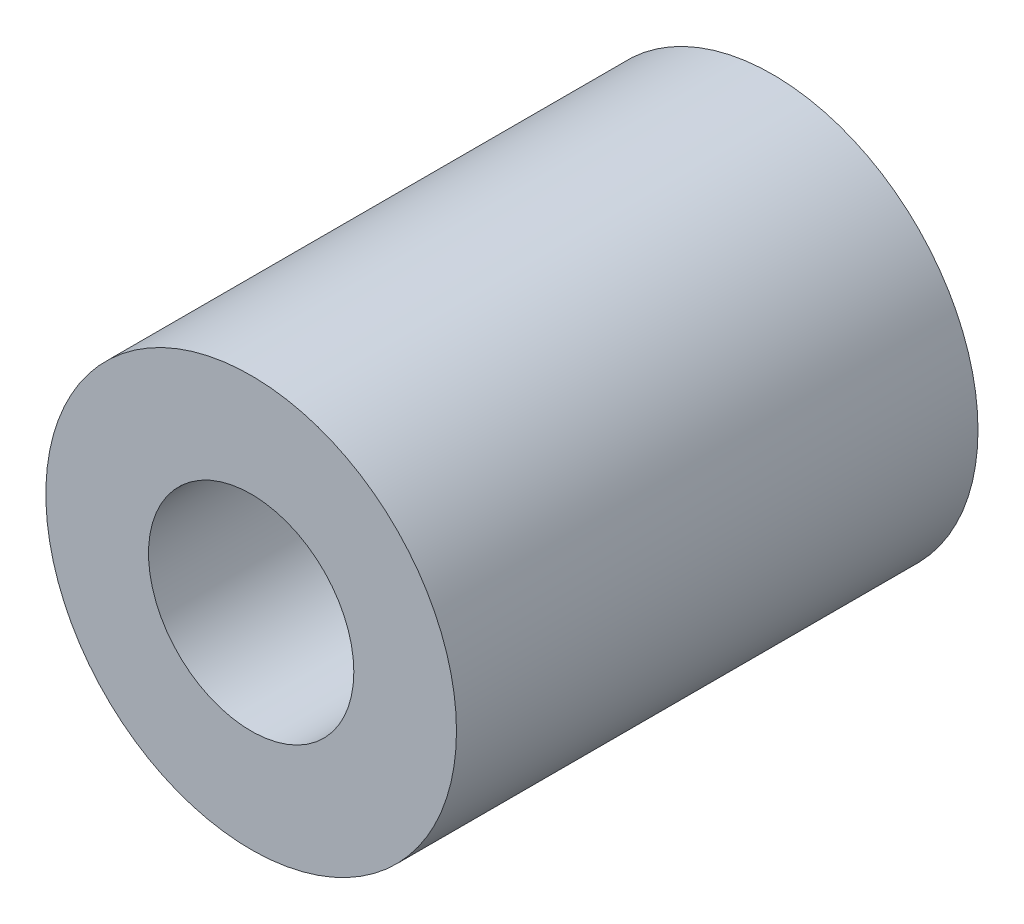
from build123d import *

# Parameters (mm, degrees)
SKETCH1_R                 = 5
BOSS_EXTRUDE1_DEPTH       = 12.7
F_5_0MM_DOWEL_HOLE1_D     = 5
F_5_0MM_DOWEL_HOLE1_DEPTH = 12.7


with BuildPart() as part:
    # Sketch1 → Boss-Extrude1 (new body)
    with BuildSketch(Plane.XY):
        Circle(SKETCH1_R)
    extrude(amount=BOSS_EXTRUDE1_DEPTH)

    # Ø5.0mm Dowel Hole1
    with Locations(Plane.XY.offset(12.7)):
        with Locations((0, 0)):
            Hole(F_5_0MM_DOWEL_HOLE1_D / 2, depth=F_5_0MM_DOWEL_HOLE1_DEPTH)


solid = part.part
